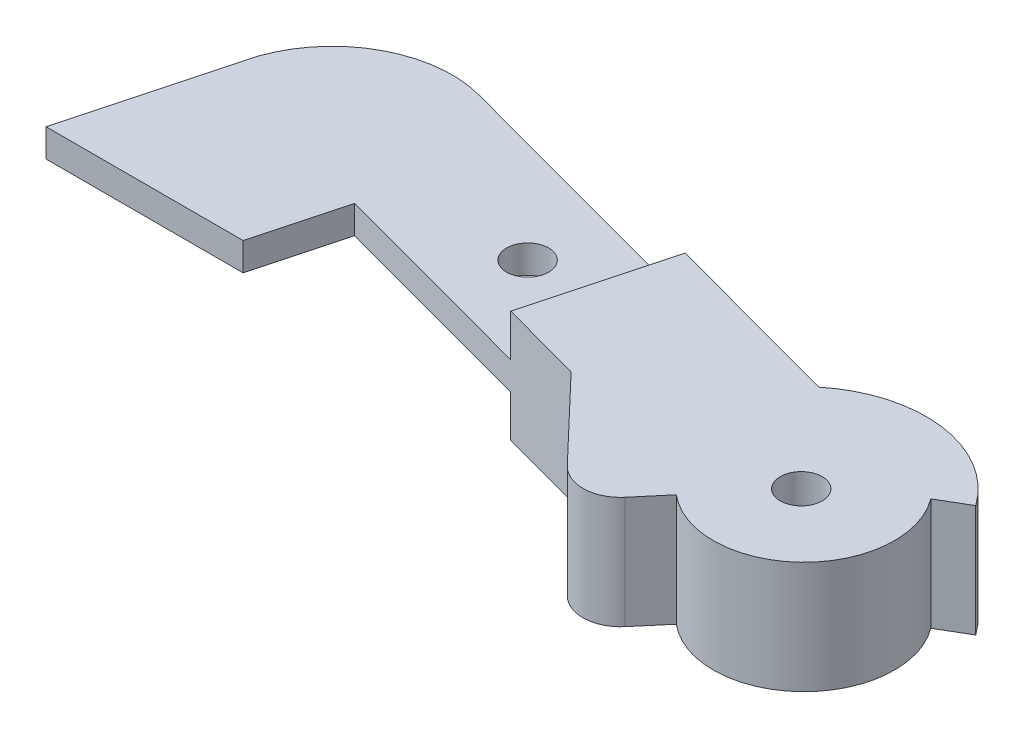
from build123d import *

# Parameters (mm, degrees)
SKETCH1_R           = 2.25
BOSS_EXTRUDE1_DEPTH = 3
SKETCH6_R           = 2.25
BOSS_EXTRUDE3_DEPTH = 4.5
BOSS_EXTRUDE4_START = -3
SKETCH6_4_R         = 2.25
BOSS_EXTRUDE4_DEPTH = 4.5


with BuildPart() as part:
    # Sketch1 → Boss-Extrude1 (new body)
    with BuildSketch(Plane(origin=(0, 0, 0), x_dir=(1, 0, 0), z_dir=(0, 1, 0))):
        with BuildLine():
            Line((4.346556407, 16.19061741), (0, 0))
            Line((0, 0), (21.097139824, 0))
            Line((21.097139824, 0), (23.621877097, 9.40446906))
            Line((23.621877097, 9.40446906), (55.315636071, 0.895916999))
            Line((55.315636071, 0.895916999), (63.837679632, -8.03903216))
            ThreePointArc((63.837679632, -8.03903216), (66.877486097, -9.287511543), (69.837996716, -7.861152194))
            Line((69.837996716, -7.861152194), (72.354139199, -4.888856081))
            ThreePointArc((72.354139199, -4.888856081), (85.255098096, -4.502096268), (86.353286495, 8.357853416))
            Line((86.353286495, 8.357853416), (89.383500932, 10.135016952))
            ThreePointArc((89.383500932, 10.135016952), (80.259194518, 15.628469331), (70.012090644, 12.72539359))
            Line((70.012090644, 12.72539359), (20.281795984, 26.10351195))
            ThreePointArc((20.281795984, 26.10351195), (10.910267874, 25.037898105), (4.794128684, 17.857792715))
            Line((4.794128684, 17.857792715), (4.346556407, 16.19061741))
        make_face()
        with Locations((78.484447615, 2.356518872)):
            Circle(SKETCH1_R, mode=Mode.SUBTRACT)
        with Locations((38.137547341, 13.414423288)):
            Circle(SKETCH1_R, mode=Mode.SUBTRACT)
    extrude(amount=BOSS_EXTRUDE1_DEPTH)

    # Sketch6 → Boss-Extrude3 (add)
    with BuildSketch(Plane(origin=(0, 3, 0), x_dir=(1, 0, 0), z_dir=(0, 1, 0))):
        with BuildLine():
            Line((46.466786902, 3.271491758), (55.315636071, 0.895916999))
            Line((55.315636071, 0.895916999), (63.837679632, -8.03903216))
            ThreePointArc((63.837679632, -8.03903216), (66.877486097, -9.287511543), (69.837996716, -7.861152194))
            Line((69.837996716, -7.861152194), (72.354139199, -4.888856081))
            ThreePointArc((72.354139199, -4.888856081), (85.255098096, -4.502096268), (86.353286495, 8.357853416))
            Line((86.353286495, 8.357853416), (89.383500932, 10.135016952))
            ThreePointArc((89.383500932, 10.135016952), (80.259194518, 15.628469331), (70.012090644, 12.72539359))
            Line((70.012090644, 12.72539359), (50.427328439, 17.993958126))
            Line((50.427328439, 17.993958126), (46.466786902, 3.271491758))
        make_face()
        with Locations((78.484447615, 2.356518872)):
            Circle(SKETCH6_R, mode=Mode.SUBTRACT)
    extrude(amount=BOSS_EXTRUDE3_DEPTH)

    # Sketch6_4 → Boss-Extrude4 (add)
    with BuildSketch(Plane(origin=(0, 3, 0), x_dir=(1, 0, 0), z_dir=(0, 1, 0)).offset(BOSS_EXTRUDE4_START)):
        with BuildLine():
            Line((46.466786902, 3.271491758), (55.315636071, 0.895916999))
            Line((55.315636071, 0.895916999), (63.837679632, -8.03903216))
            ThreePointArc((63.837679632, -8.03903216), (66.877486097, -9.287511543), (69.837996716, -7.861152194))
            Line((69.837996716, -7.861152194), (72.354139199, -4.888856081))
            ThreePointArc((72.354139199, -4.888856081), (85.255098096, -4.502096268), (86.353286495, 8.357853416))
            Line((86.353286495, 8.357853416), (89.383500932, 10.135016952))
            ThreePointArc((89.383500932, 10.135016952), (80.259194518, 15.628469331), (70.012090644, 12.72539359))
            Line((70.012090644, 12.72539359), (50.427328439, 17.993958126))
            Line((50.427328439, 17.993958126), (46.466786902, 3.271491758))
        make_face()
        with Locations((78.484447615, 2.356518872)):
            Circle(SKETCH6_4_R, mode=Mode.SUBTRACT)
    extrude(amount=-BOSS_EXTRUDE4_DEPTH)


solid = part.part
